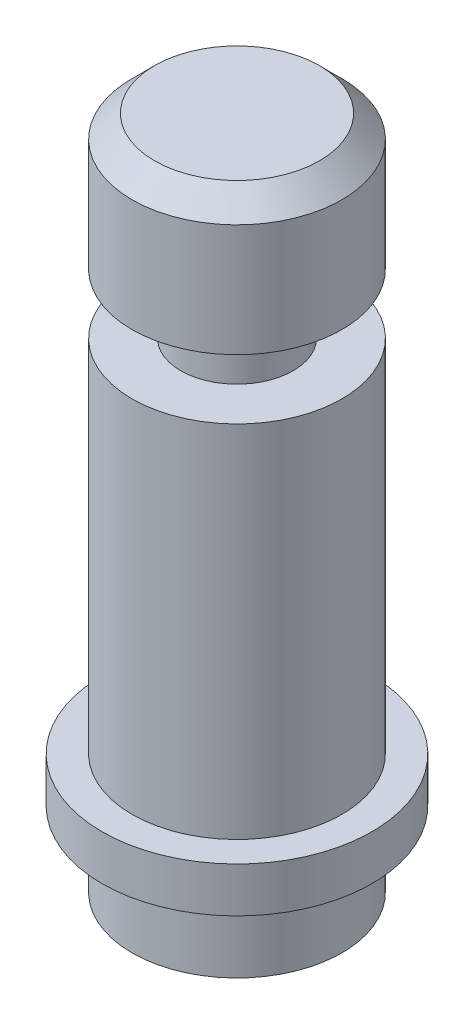
from build123d import *

# Parameters (mm, degrees)
CROQUIS1_R              = 9
SALIENTE_EXTRUIR1_DEPTH = 3
CROQUIS2_R              = 7
SALIENTE_EXTRUIR2_DEPTH = 27
CROQUIS4_R              = 3.75
SALIENTE_EXTRUIR3_DEPTH = 4
CROQUIS5_R              = 7
SALIENTE_EXTRUIR4_DEPTH = 9
CROQUIS7_R              = 7
SALIENTE_EXTRUIR5_DEPTH = 5
CHAFL_N1_SIZE           = 1.5


with BuildPart() as part:
    # Croquis1 → Saliente-Extruir1 (new body)
    with BuildSketch(Plane(origin=(0, 0, 0), x_dir=(1, 0, 0), z_dir=(0, 1, 0))):
        Circle(CROQUIS1_R)
    extrude(amount=SALIENTE_EXTRUIR1_DEPTH)

    # Croquis2 → Saliente-Extruir2 (add)
    with BuildSketch(Plane(origin=(0, 0, 0), x_dir=(1, 0, 0), z_dir=(0, 1, 0))):
        Circle(CROQUIS2_R)
    extrude(amount=SALIENTE_EXTRUIR2_DEPTH)

    # Croquis4 → Saliente-Extruir3 (add)
    with BuildSketch(Plane(origin=(0, 27, 0), x_dir=(1, 0, 0), z_dir=(0, 1, 0))):
        Circle(CROQUIS4_R)
    extrude(amount=SALIENTE_EXTRUIR3_DEPTH)

    # Croquis5 → Saliente-Extruir4 (add)
    with BuildSketch(Plane(origin=(0, 31, 0), x_dir=(1, 0, 0), z_dir=(0, 1, 0))):
        Circle(CROQUIS5_R)
    extrude(amount=SALIENTE_EXTRUIR4_DEPTH)

    # Croquis7 → Saliente-Extruir5 (add)
    with BuildSketch(Plane.XZ):
        Circle(CROQUIS7_R)
    extrude(amount=SALIENTE_EXTRUIR5_DEPTH)

    # Chaflán1
    chafl_n1_edges = [part.edges().sort_by_distance(p)[0] for p in [
        (-7, 40, 0),
    ]]
    chamfer(chafl_n1_edges, length=CHAFL_N1_SIZE)


solid = part.part
